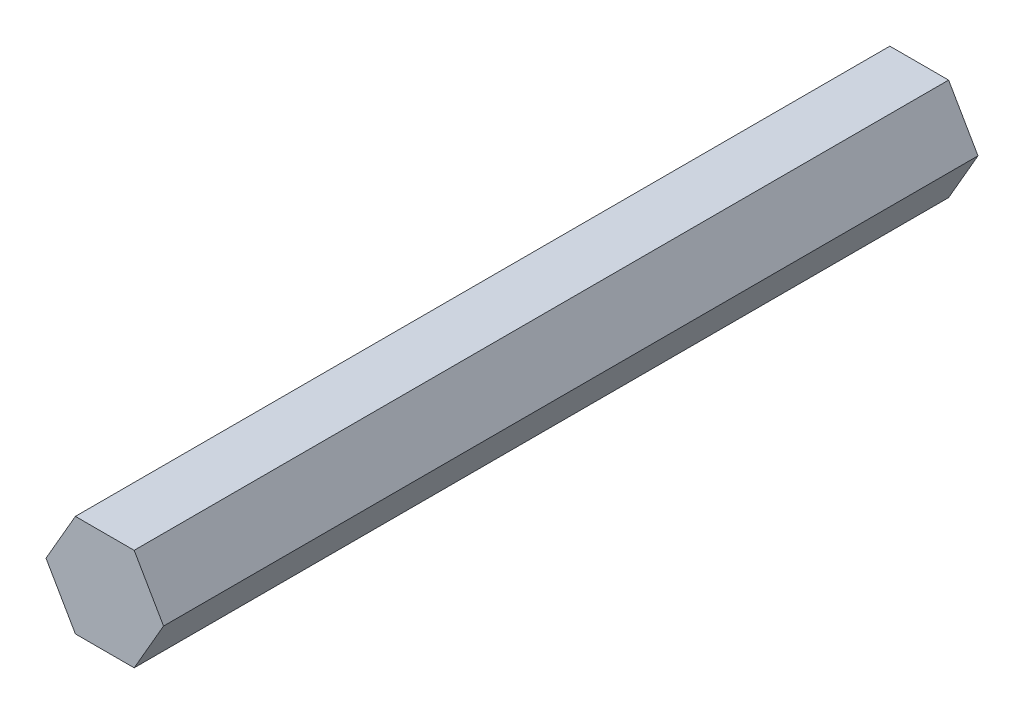
from build123d import *

# Parameters (mm, degrees)
BOSS_EXTRUDE1_DEPTH = 101.6


with BuildPart() as part:
    # Sketch1 → Boss-Extrude1 (new body)
    with BuildSketch(Plane.XY):
        Polygon((7.332348419, 0), (3.666174209, 6.35), (-3.666174209, 6.35), (-7.332348419, 0), (-3.666174209, -6.35), (3.666174209, -6.35), align=None)
    extrude(amount=BOSS_EXTRUDE1_DEPTH)


solid = part.part
